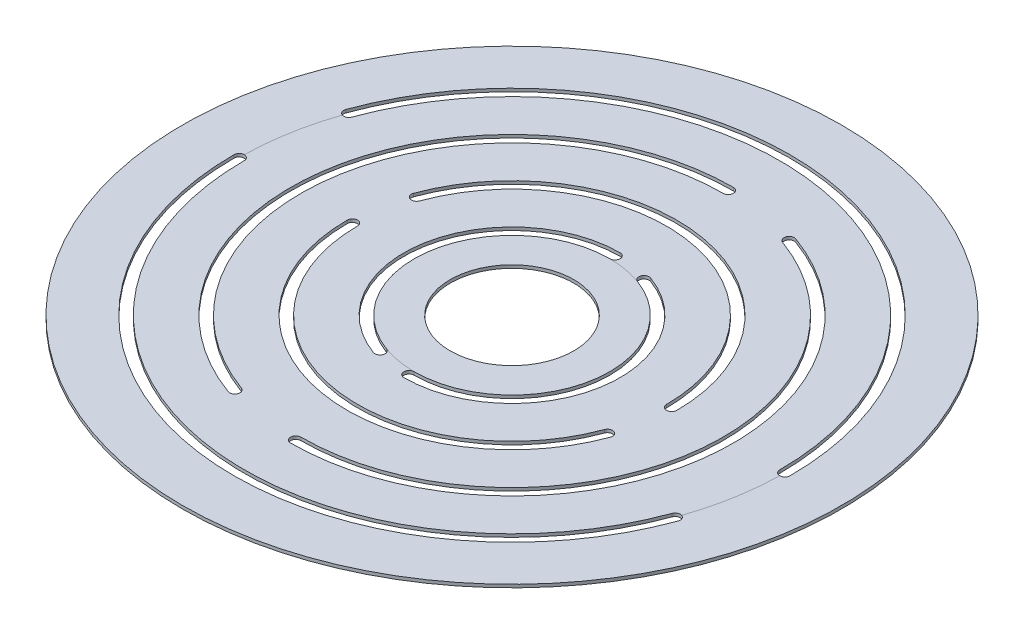
from build123d import *

# Parameters (mm, degrees)
SKETCH1_R           = 32
SKETCH1_R_2         = 6
BOSS_EXTRUDE1_DEPTH = 0.3


with BuildPart() as part:
    # Sketch1 → Boss-Extrude1 (new body)
    with BuildSketch(Plane(origin=(0, 0, 0), x_dir=(1, 0, 0), z_dir=(0, 1, 0))):
        Circle(SKETCH1_R)
        Circle(SKETCH1_R_2, mode=Mode.SUBTRACT)
        with BuildLine():
            ThreePointArc((27, 0), (4.688500797, 26.589809331), (-25.371700761, 9.23454387))
            ThreePointArc((-25.371700761, 9.23454387), (-25.072864522, 8.593687488), (-24.43200814, 8.892523726))
            ThreePointArc((-24.43200814, 8.892523726), (4.514852619, 25.605001578), (26, 0))
            ThreePointArc((26, 0), (26.5, -0.5), (27, 0))
        make_face(mode=Mode.SUBTRACT)
        with BuildLine():
            ThreePointArc((0, 21.5), (-21.17336669, 3.73343582), (-7.353433082, -20.203391347))
            ThreePointArc((-7.353433082, -20.203391347), (-6.712576699, -19.904555108), (-7.011412938, -19.263698726))
            ThreePointArc((-7.011412938, -19.263698726), (-20.188558937, 3.559787642), (0, 20.5))
            ThreePointArc((0, 20.5), (0.5, 21), (0, 21.5))
        make_face(mode=Mode.SUBTRACT)
        with BuildLine():
            ThreePointArc((16, 0), (2.778370843, 15.756924048), (-15.035081933, 5.472322293))
            ThreePointArc((-15.035081933, 5.472322293), (-14.736245694, 4.831465911), (-14.095389312, 5.13030215))
            ThreePointArc((-14.095389312, 5.13030215), (2.604722665, 14.772116295), (15, 0))
            ThreePointArc((15, 0), (15.5, -0.5), (16, 0))
        make_face(mode=Mode.SUBTRACT)
        with BuildLine():
            ThreePointArc((0, -21.5), (21.17336669, -3.73343582), (7.353433082, 20.203391347))
            ThreePointArc((7.353433082, 20.203391347), (6.712576699, 19.904555108), (7.011412938, 19.263698726))
            ThreePointArc((7.011412938, 19.263698726), (20.188558937, -3.559787642), (0, -20.5))
            ThreePointArc((0, -20.5), (-0.5, -21), (0, -21.5))
        make_face(mode=Mode.SUBTRACT)
        with BuildLine():
            ThreePointArc((0, 10.5), (-10.340481407, 1.823305866), (-3.591211505, -9.866772518))
            ThreePointArc((-3.591211505, -9.866772518), (-2.950355123, -9.56793628), (-3.249191362, -8.927079897))
            ThreePointArc((-3.249191362, -8.927079897), (-9.355673654, 1.649657688), (0, 9.5))
            ThreePointArc((0, 9.5), (0.5, 10), (0, 10.5))
        make_face(mode=Mode.SUBTRACT)
        with BuildLine():
            ThreePointArc((0, -10.5), (10.340481407, -1.823305866), (3.591211505, 9.866772518))
            ThreePointArc((3.591211505, 9.866772518), (2.950355123, 9.56793628), (3.249191362, 8.927079897))
            ThreePointArc((3.249191362, 8.927079897), (9.355673654, -1.649657688), (0, -9.5))
            ThreePointArc((0, -9.5), (-0.5, -10), (0, -10.5))
        make_face(mode=Mode.SUBTRACT)
        with BuildLine():
            ThreePointArc((-16, 0), (-2.778370843, -15.756924048), (15.035081933, -5.472322293))
            ThreePointArc((15.035081933, -5.472322293), (14.736245694, -4.831465911), (14.095389312, -5.13030215))
            ThreePointArc((14.095389312, -5.13030215), (-2.604722665, -14.772116295), (-15, 0))
            ThreePointArc((-15, 0), (-15.5, 0.5), (-16, 0))
        make_face(mode=Mode.SUBTRACT)
        with BuildLine():
            ThreePointArc((-27, 0), (-4.688500797, -26.589809331), (25.371700761, -9.23454387))
            ThreePointArc((25.371700761, -9.23454387), (25.072864522, -8.593687488), (24.43200814, -8.892523726))
            ThreePointArc((24.43200814, -8.892523726), (-4.514852619, -25.605001578), (-26, 0))
            ThreePointArc((-26, 0), (-26.5, 0.5), (-27, 0))
        make_face(mode=Mode.SUBTRACT)
    extrude(amount=BOSS_EXTRUDE1_DEPTH)


solid = part.part
